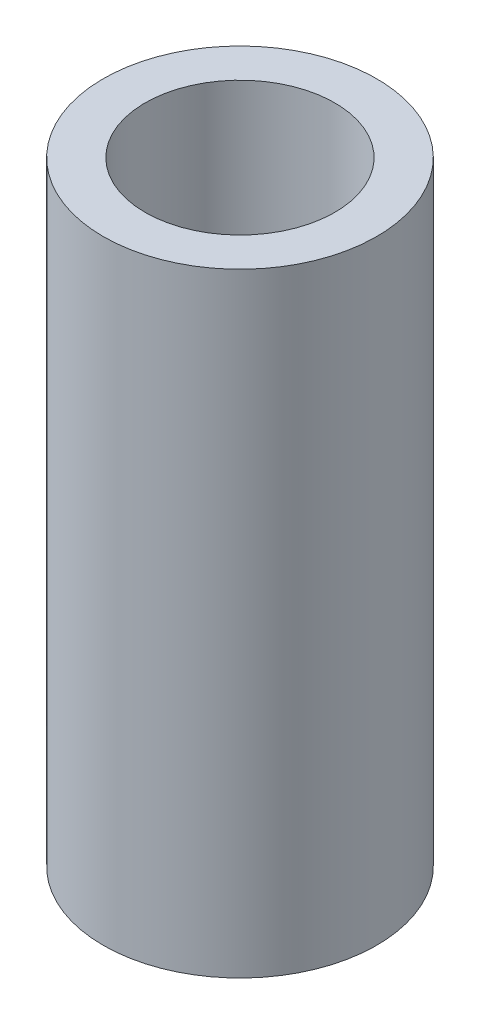
from build123d import *

# Parameters (mm, degrees)
SKETCH1_R           = 2.45
SKETCH1_R_2         = 1.7
BOSS_EXTRUDE1_DEPTH = 11


with BuildPart() as part:
    # Sketch1 → Boss-Extrude1 (new body)
    with BuildSketch(Plane(origin=(0, 0, 0), x_dir=(1, 0, 0), z_dir=(0, 1, 0))):
        Circle(SKETCH1_R)
        Circle(SKETCH1_R_2, mode=Mode.SUBTRACT)
    extrude(amount=BOSS_EXTRUDE1_DEPTH)


solid = part.part
